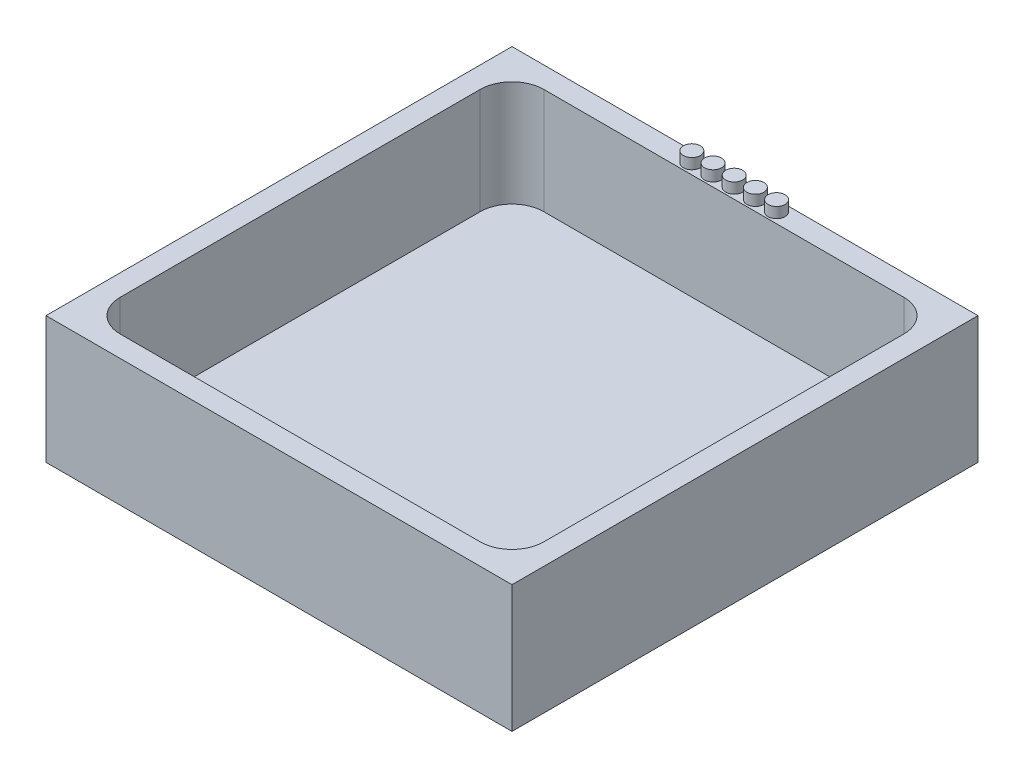
from build123d import *

# Parameters (mm, degrees)
SKETCH1_W           = 20
SKETCH1_H           = 20
BOSS_EXTRUDE2_DEPTH = 1
SKETCH1_6_W         = 22
SKETCH1_6_H         = 22
SKETCH1_6_W_2       = 20
SKETCH1_6_H_2       = 20
BOSS_EXTRUDE3_DEPTH = 6
SKETCH2_R           = 0.4
BOSS_EXTRUDE4_DEPTH = 0.5
FILLET1_R           = 1.5


with BuildPart() as part:
    # Sketch1 → Boss-Extrude2 (new body)
    with BuildSketch(Plane(origin=(0, 0, 0), x_dir=(1, 0, 0), z_dir=(0, 1, 0))):
        Rectangle(SKETCH1_W, SKETCH1_H)
    extrude(amount=BOSS_EXTRUDE2_DEPTH)

    # Sketch1_6 → Boss-Extrude3 (add)
    with BuildSketch(Plane(origin=(0, 0, 0), x_dir=(1, 0, 0), z_dir=(0, 1, 0))):
        Rectangle(SKETCH1_6_W, SKETCH1_6_H)
        Rectangle(SKETCH1_6_W_2, SKETCH1_6_H_2, mode=Mode.SUBTRACT)
    extrude(amount=BOSS_EXTRUDE3_DEPTH)

    # Sketch2 → Boss-Extrude4 (add)
    with BuildSketch(Plane(origin=(0, 6, 0), x_dir=(1, 0, 0), z_dir=(0, 1, 0))):
        with Locations((0, 10.490155688)):
            Circle(SKETCH2_R)
        with Locations((1, 10.490155688)):
            Circle(SKETCH2_R)
        with Locations((-1, 10.490155688)):
            Circle(SKETCH2_R)
        with Locations((-2, 10.490155688)):
            Circle(SKETCH2_R)
        with Locations((2, 10.490155688)):
            Circle(SKETCH2_R)
    extrude(amount=BOSS_EXTRUDE4_DEPTH)

    # Fillet1
    fillet1_edges = [part.edges().sort_by_distance(p)[0] for p in [
        (10, 3.5, -10),
        (-10, 3.5, -10),
        (-10, 3.5, 10),
        (10, 3.5, 10),
    ]]
    fillet(fillet1_edges, radius=FILLET1_R)


solid = part.part
